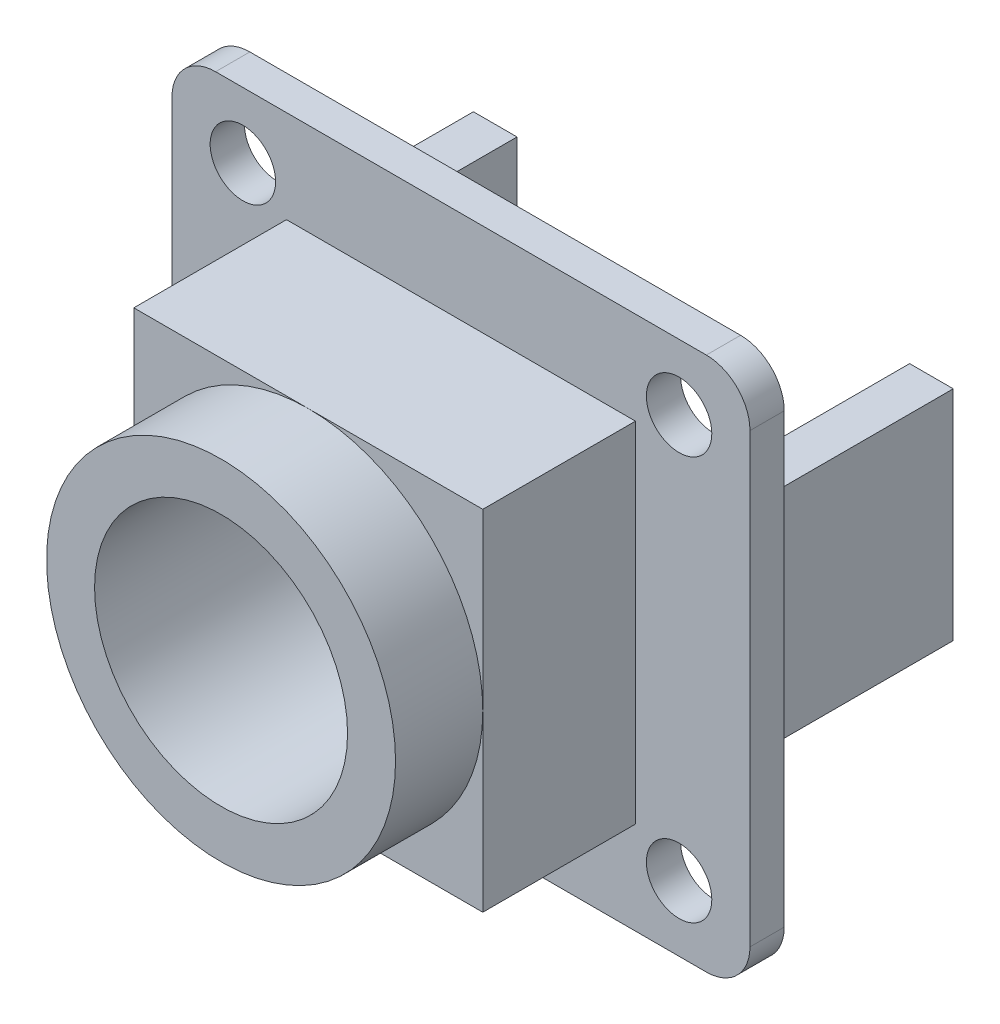
from build123d import *

# Parameters (mm, degrees)
SKETCH_1_W          = 26.5
SKETCH_1_H          = 24.5
SKETCH_1_R          = 1.5
EXTRUDE_1_DEPTH     = 1.57
SKETCH_3_W          = 16
SKETCH_3_H          = 16
EXTRUDE_2_DEPTH     = 7
SKETCH_4_R          = 8
EXTRUDE_3_DEPTH     = 4
SKETCH_5_R          = 5.8
CUT_EXTRUDE_1_DEPTH = 11
FILLET_1_R          = 2
SKETCH_6_W          = 2
SKETCH_6_H          = 10
EXTRUDE_4_DEPTH     = 10


with BuildPart() as part:
    # 草图1 → 凸台-拉伸1 (new body)
    with BuildSketch(Plane.XY):
        Rectangle(SKETCH_1_W, SKETCH_1_H)
        with Locations((-10, 9.25)):
            Circle(SKETCH_1_R, mode=Mode.SUBTRACT)
        with Locations((10, 9.25)):
            Circle(SKETCH_1_R, mode=Mode.SUBTRACT)
        with Locations((10, -9.25)):
            Circle(SKETCH_1_R, mode=Mode.SUBTRACT)
        with Locations((-10, -9.25)):
            Circle(SKETCH_1_R, mode=Mode.SUBTRACT)
    extrude(amount=EXTRUDE_1_DEPTH)

    # 草图3 → 凸台-拉伸2 (add)
    with BuildSketch(Plane.XY.offset(1.57)):
        Rectangle(SKETCH_3_W, SKETCH_3_H)
    extrude(amount=EXTRUDE_2_DEPTH)

    # 草图4 → 凸台-拉伸3 (add)
    with BuildSketch(Plane.XY.offset(8.57)):
        Circle(SKETCH_4_R)
    extrude(amount=EXTRUDE_3_DEPTH)

    # 草图5 → 切除-拉伸1 (cut)
    with BuildSketch(Plane.XY.offset(12.57)):
        Circle(SKETCH_5_R)
    extrude(amount=-CUT_EXTRUDE_1_DEPTH, mode=Mode.SUBTRACT)

    # 圆角1
    fillet_1_edges = [part.edges().sort_by_distance(p)[0] for p in [
        (13.25, -12.25, 0.785),
        (-13.25, -12.25, 0.785),
        (-13.25, 12.25, 0.785),
        (13.25, 12.25, 0.785),
    ]]
    fillet(fillet_1_edges, radius=FILLET_1_R)

    # 草图6 → 凸台-拉伸4 (add)
    with BuildSketch(Plane(origin=(0, 0, 0), x_dir=(-1, 0, 0), z_dir=(0, 0, -1))):
        with Locations((-10, 0)):
            Rectangle(SKETCH_6_W, SKETCH_6_H)
        with Locations((10, 0)):
            Rectangle(SKETCH_6_W, SKETCH_6_H)
    extrude(amount=EXTRUDE_4_DEPTH)


solid = part.part
